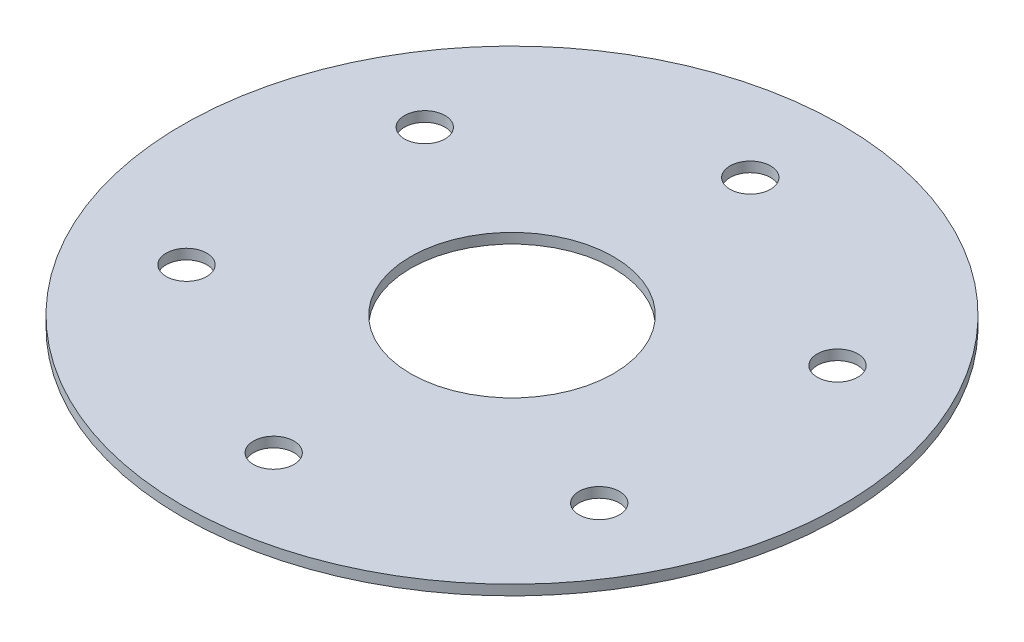
from build123d import *

# Parameters (mm, degrees)
SKETCH1_R           = 32.5
SKETCH1_R_2         = 10
SKETCH1_R_3         = 2
BOSS_EXTRUDE1_DEPTH = 1


with BuildPart() as part:
    # Sketch1 → Boss-Extrude1 (new body)
    with BuildSketch(Plane(origin=(0, 0, 0), x_dir=(1, 0, 0), z_dir=(0, 1, 0))):
        Circle(SKETCH1_R)
        Circle(SKETCH1_R_2, mode=Mode.SUBTRACT)
        with Locations((0, 23.5)):
            Circle(SKETCH1_R_3, mode=Mode.SUBTRACT)
        with Locations((20.351596989, 11.75)):
            Circle(SKETCH1_R_3, mode=Mode.SUBTRACT)
        with Locations((20.351596989, -11.75)):
            Circle(SKETCH1_R_3, mode=Mode.SUBTRACT)
        with Locations((0, -23.5)):
            Circle(SKETCH1_R_3, mode=Mode.SUBTRACT)
        with Locations((-20.351596989, -11.75)):
            Circle(SKETCH1_R_3, mode=Mode.SUBTRACT)
        with Locations((-20.351596989, 11.75)):
            Circle(SKETCH1_R_3, mode=Mode.SUBTRACT)
    extrude(amount=BOSS_EXTRUDE1_DEPTH)


solid = part.part
